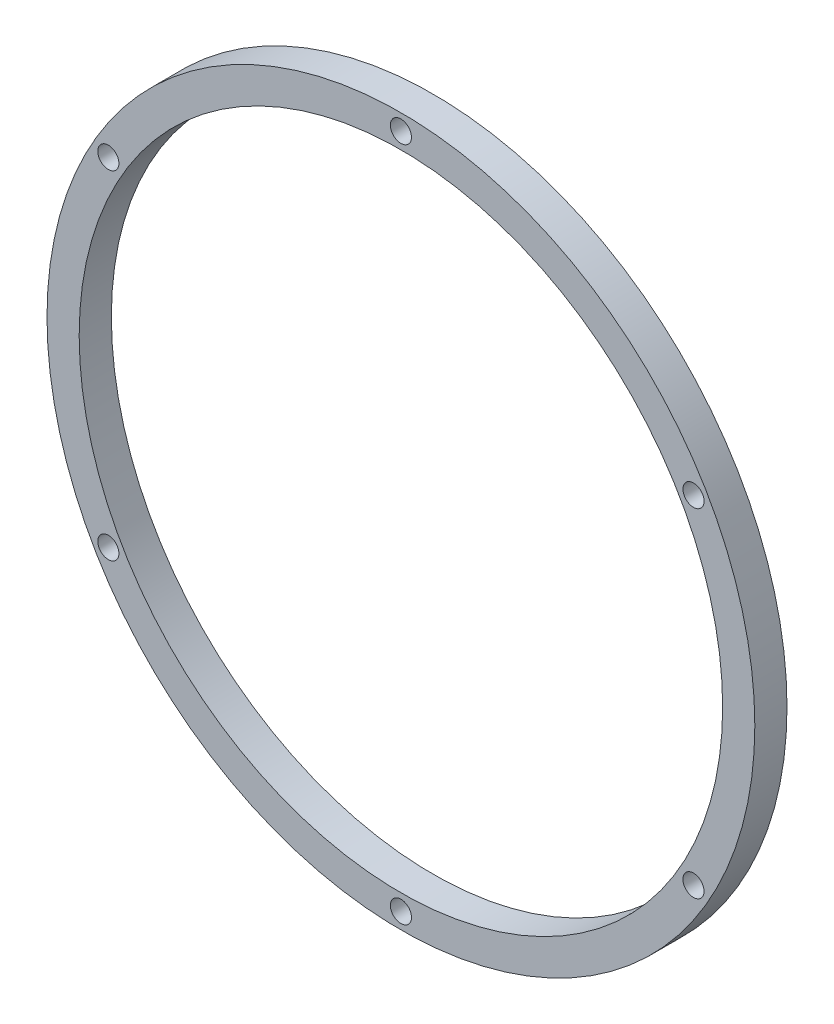
from build123d import *

# Parameters (mm, degrees)
SKETCH1_R           = 69.85
SKETCH1_R_2         = 63.5
BOSS_EXTRUDE1_DEPTH = 6.35
SKETCH2_R           = 2.085
CUT_EXTRUDE1_DEPTH  = 21.336


with BuildPart() as part:
    # Sketch1 → Boss-Extrude1 (new body)
    with BuildSketch(Plane.XY):
        with Locations((26.627424347, 39.834794984)):
            Circle(SKETCH1_R)
        with Locations((26.627424347, 39.834794984)):
            Circle(SKETCH1_R_2, mode=Mode.SUBTRACT)
    extrude(amount=BOSS_EXTRUDE1_DEPTH)

    # Sketch2 → Cut-Extrude1 (cut)
    with BuildSketch(Plane.XY.offset(6.35)):
        with Locations((26.627424347, 106.509794984)):
            Circle(SKETCH2_R)
        with Locations((84.369668144, 73.172294984)):
            Circle(SKETCH2_R)
        with Locations((84.369668144, 6.497294984)):
            Circle(SKETCH2_R)
        with Locations((26.627424347, -26.840205016)):
            Circle(SKETCH2_R)
        with Locations((-31.11481945, 6.497294984)):
            Circle(SKETCH2_R)
        with Locations((-31.11481945, 73.172294984)):
            Circle(SKETCH2_R)
    extrude(amount=-CUT_EXTRUDE1_DEPTH, mode=Mode.SUBTRACT)


solid = part.part
